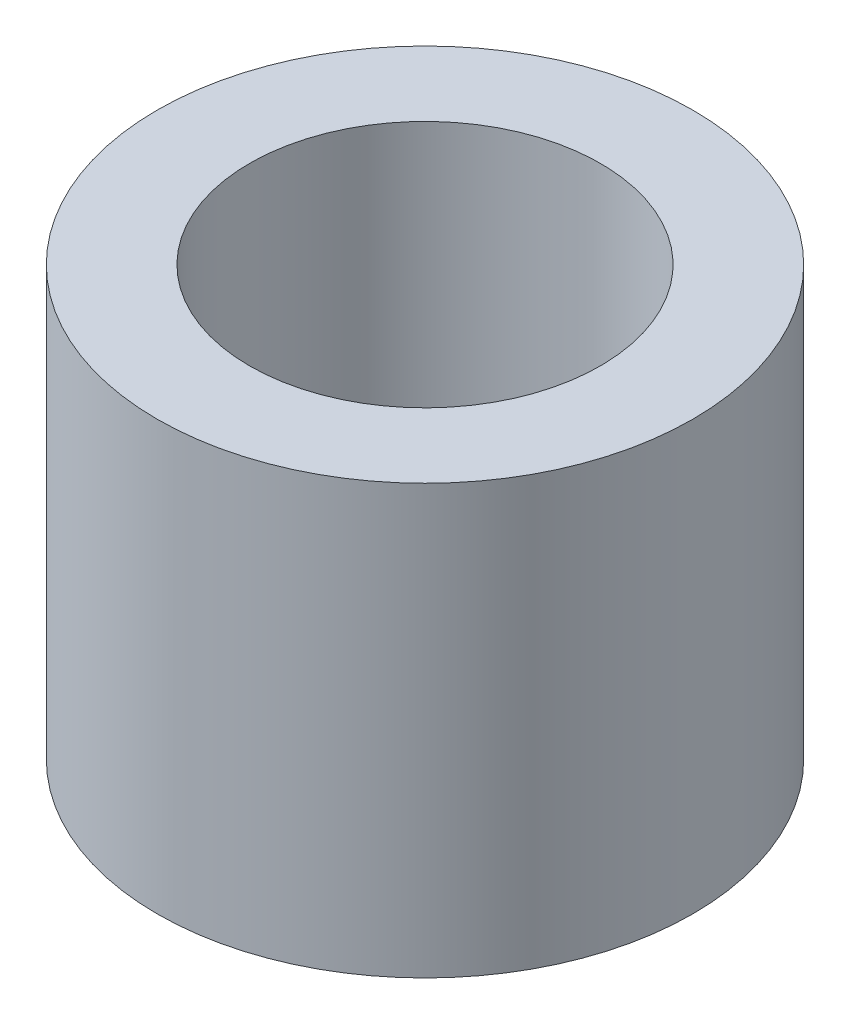
from build123d import *

# Parameters (mm, degrees)
SKETCH1_R           = 3.96875
SKETCH1_R_2         = 2.6
BOSS_EXTRUDE1_DEPTH = 6.35


with BuildPart() as part:
    # Sketch1 → Boss-Extrude1 (new body)
    with BuildSketch(Plane(origin=(0, 0, 0), x_dir=(1, 0, 0), z_dir=(0, 1, 0))):
        Circle(SKETCH1_R)
        Circle(SKETCH1_R_2, mode=Mode.SUBTRACT)
    extrude(amount=BOSS_EXTRUDE1_DEPTH)


solid = part.part
